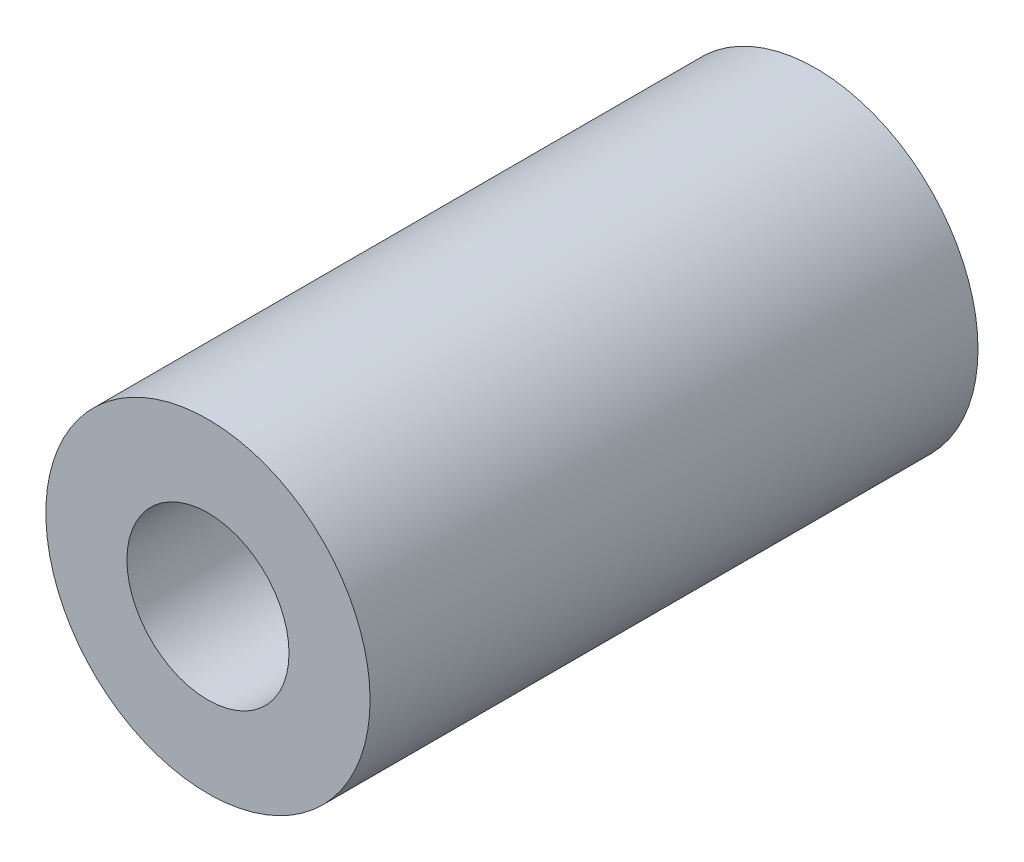
from build123d import *

# Parameters (mm, degrees)
SKETCH_1_R      = 4
SKETCH_1_R_2    = 2
EXTRUDE_1_DEPTH = 7.5


with BuildPart() as part:
    # 草图1 → 凸台-拉伸1 (new body, symmetric)
    with BuildSketch(Plane.XY):
        Circle(SKETCH_1_R)
        Circle(SKETCH_1_R_2, mode=Mode.SUBTRACT)
    extrude(amount=EXTRUDE_1_DEPTH, both=True)


solid = part.part
